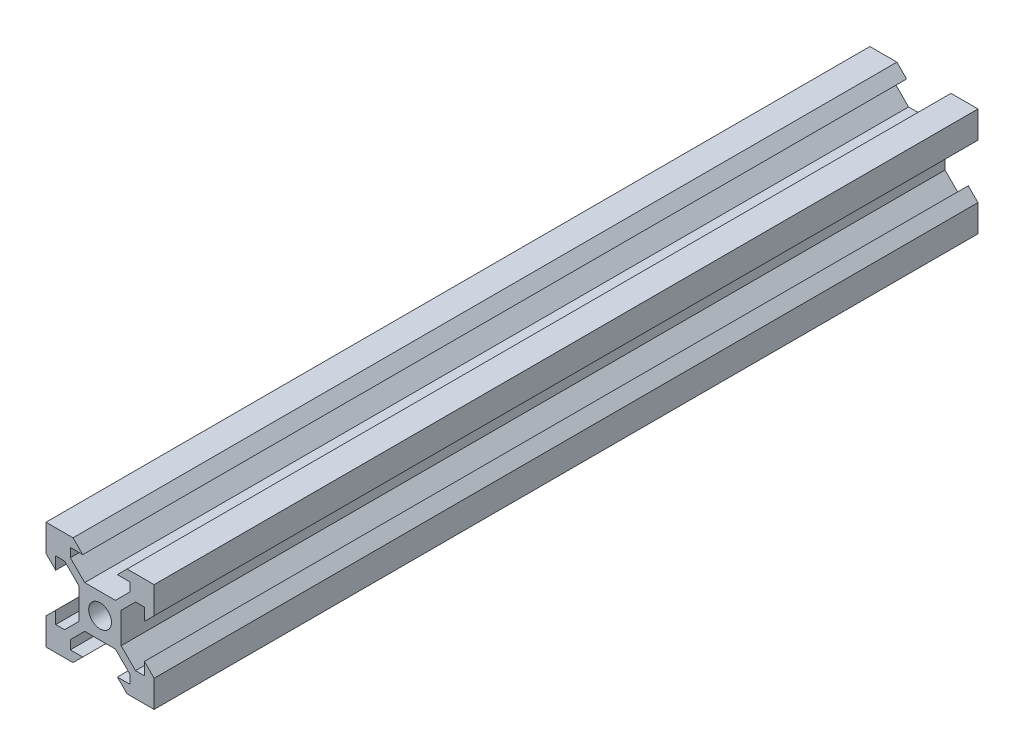
from build123d import *

# Parameters (mm, degrees)
SKETCH1_R           = 2.1
BOSS_EXTRUDE1_DEPTH = 76.2


with BuildPart() as part:
    # Sketch1 → Boss-Extrude1 (new body, symmetric)
    with BuildSketch(Plane.XY):
        Polygon((-10, 10), (-5, 10), (-3.2, 8.2), (-5.499339828, 8.2), (-5.499339828, 6.56), (-2.84, 3.900660172), (2.84, 3.900660172), (5.499339828, 6.56), (5.499339828, 8.2), (3.2, 8.2), (5, 10), (10, 10), (10, 5), (8.2, 3.2), (8.2, 5.499339828), (6.56, 5.499339828), (3.900660172, 2.84), (3.900660172, -2.84), (6.56, -5.499339828), (8.2, -5.499339828), (8.2, -3.2), (10, -5), (10, -10), (5, -10), (3.2, -8.2), (5.499339828, -8.2), (5.499339828, -6.56), (2.84, -3.900660172), (-2.84, -3.900660172), (-5.499339828, -6.56), (-5.499339828, -8.2), (-3.2, -8.2), (-5, -10), (-10, -10), (-10, -5), (-8.2, -3.2), (-8.2, -5.499339828), (-6.56, -5.499339828), (-3.900660172, -2.84), (-3.900660172, 2.84), (-6.56, 5.499339828), (-8.2, 5.499339828), (-8.2, 3.2), (-10, 5), align=None)
        Circle(SKETCH1_R, mode=Mode.SUBTRACT)
    extrude(amount=BOSS_EXTRUDE1_DEPTH, both=True)


solid = part.part
